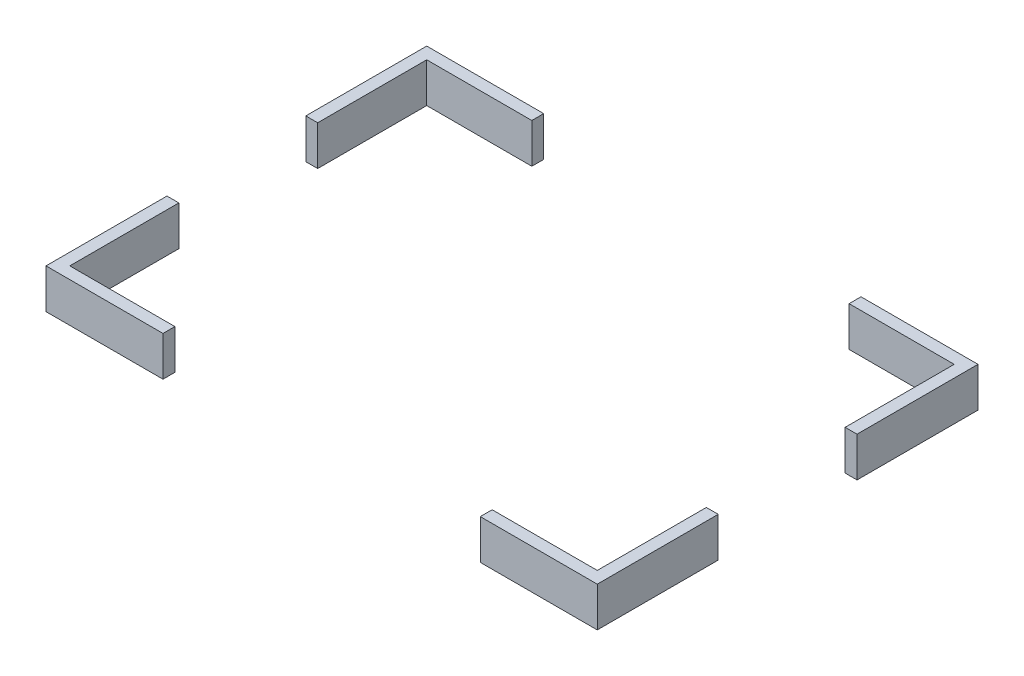
from build123d import *

# Parameters (mm, degrees)
SKETCH1_W           = 139
SKETCH1_H           = 96
SKETCH1_W_2         = 133
SKETCH1_H_2         = 90
BOSS_EXTRUDE1_DEPTH = 10
SKETCH2_W           = 35
SKETCH2_H           = 30
CUT_EXTRUDE1_DEPTH  = 600
SKETCH3_W           = 80
SKETCH3_H           = 120.605427014
CUT_EXTRUDE2_DEPTH  = 50


with BuildPart() as part:
    # Sketch1 → Boss-Extrude1 (new body)
    with BuildSketch(Plane(origin=(0, 0, 0), x_dir=(1, 0, 0), z_dir=(0, 1, 0))):
        Rectangle(SKETCH1_W, SKETCH1_H)
        Rectangle(SKETCH1_W_2, SKETCH1_H_2, mode=Mode.SUBTRACT)
    extrude(amount=BOSS_EXTRUDE1_DEPTH)

    # Sketch2 → Cut-Extrude1 (cut)
    with BuildSketch(Plane(origin=(69.5, 0, 0), x_dir=(0, 0, -1), z_dir=(1, 0, 0))):
        Rectangle(SKETCH2_W, SKETCH2_H)
    extrude(amount=-CUT_EXTRUDE1_DEPTH, mode=Mode.SUBTRACT)

    # Sketch3 → Cut-Extrude2 (cut)
    with BuildSketch(Plane(origin=(0, 10, 0), x_dir=(1, 0, 0), z_dir=(0, 1, 0))):
        with Locations((0, -1.453077434)):
            Rectangle(SKETCH3_W, SKETCH3_H)
    extrude(amount=-CUT_EXTRUDE2_DEPTH, mode=Mode.SUBTRACT)


solid = part.part
